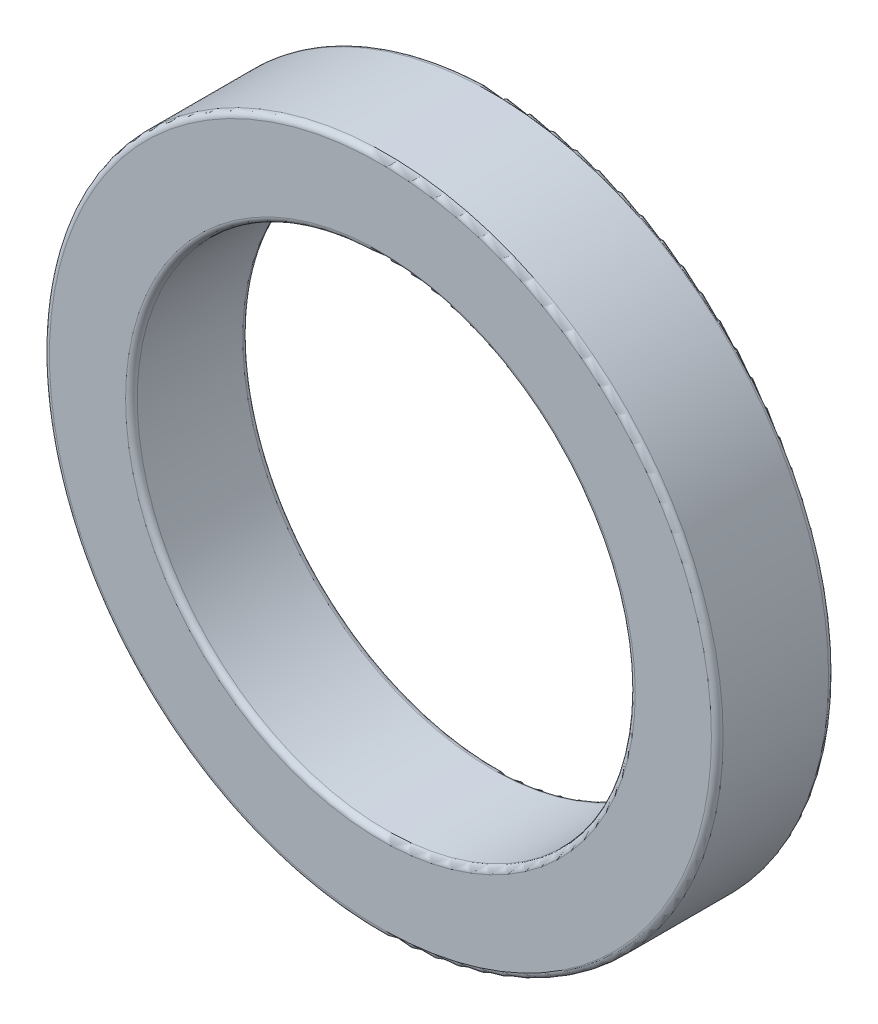
from build123d import *

# Parameters (mm, degrees)
SKETCH_1_R      = 11.5
SKETCH_1_R_2    = 8.5
EXTRUDE_1_DEPTH = 4
FILLET_1_R      = 0.2


with BuildPart() as part:
    # 草图1 → 凸台-拉伸1 (new body)
    with BuildSketch(Plane.XY):
        Circle(SKETCH_1_R)
        Circle(SKETCH_1_R_2, mode=Mode.SUBTRACT)
    extrude(amount=EXTRUDE_1_DEPTH)

    # 圆角1
    fillet_1_edges = [part.edges().sort_by_distance(p)[0] for p in [
        (-11.5, 0, 0),
        (-11.5, 0, 4),
        (-8.5, 0, 0),
        (-8.5, 0, 4),
    ]]
    fillet(fillet_1_edges, radius=FILLET_1_R)


solid = part.part
